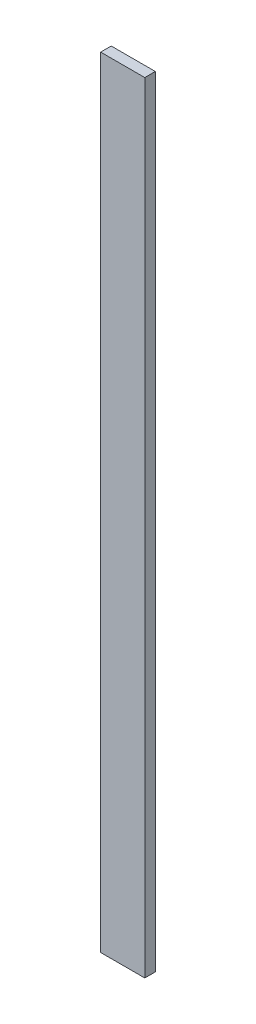
from build123d import *

# Parameters (mm, degrees)
SKETCH1_W           = 6.35
SKETCH1_H           = 1.51892
BOSS_EXTRUDE1_DEPTH = 112.268


with BuildPart() as part:
    # Sketch1 → Boss-Extrude1 (new body)
    with BuildSketch(Plane(origin=(0, 0, 0), x_dir=(1, 0, 0), z_dir=(0, 1, 0))):
        with Locations((3.175, 0.75946)):
            Rectangle(SKETCH1_W, SKETCH1_H)
    extrude(amount=BOSS_EXTRUDE1_DEPTH)


solid = part.part
